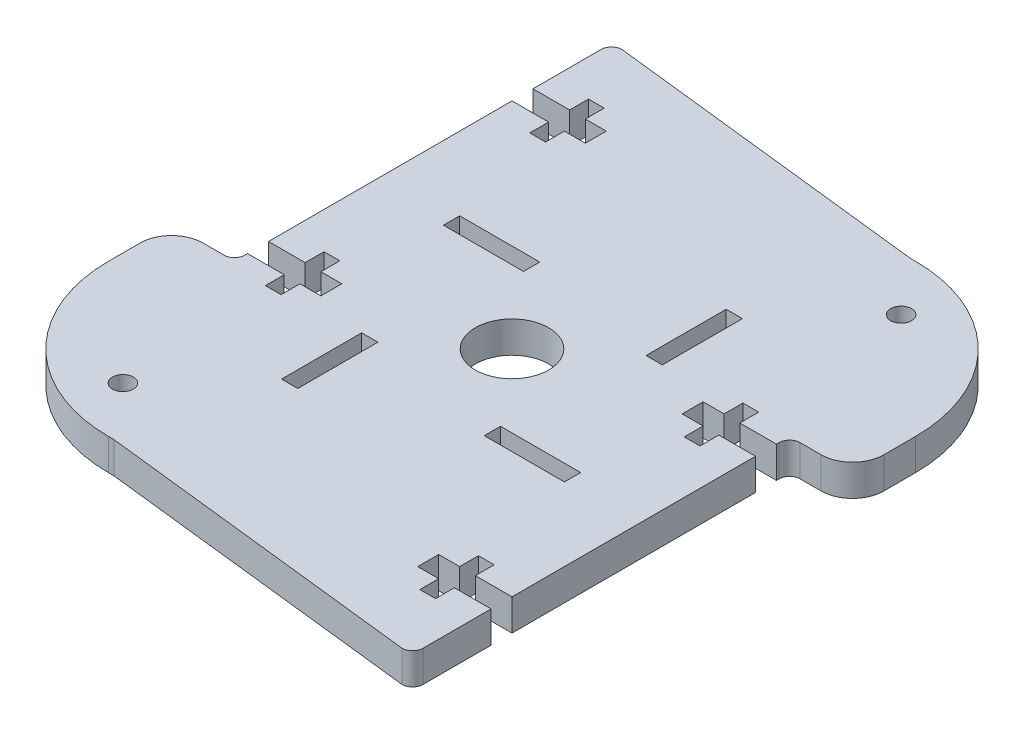
from build123d import *

# Parameters (mm, degrees)
ESBO_O1_W                = 53
ESBO_O1_H                = 60
RESSALTO_EXTRUS_O1_DEPTH = 3
ESBO_O4_W                = 1.55
ESBO_O4_H                = 7.65
ESBO_O4_W_2              = 7.65
ESBO_O4_H_2              = 1.55
CORTE_EXTRUS_O2_DEPTH    = 10
ESBO_O5_R                = 1
CORTE_EXTRUS_O3_DEPTH    = 41.140378673
ESBO_O7_R                = 3.5
CORTE_EXTRUS_O6_DEPTH    = 41.140378673
ESBO_O8_W                = 6
ESBO_O8_H                = 36
CORTE_EXTRUS_O7_DEPTH    = 41.140378673
FILETE2_R                = 3
FILETE3_R                = 1
CORTE_EXTRUS_O8_DEPTH    = 41.140378673
CORTE_EXTRUS_O9_DEPTH    = 41.140378673


with BuildPart() as part:
    # Esboço1 → Ressalto-extrusão1 (new body)
    with BuildSketch(Plane(origin=(0, 0, 0), x_dir=(1, 0, 0), z_dir=(0, 1, 0))):
        Rectangle(ESBO_O1_W, ESBO_O1_H)
    extrude(amount=RESSALTO_EXTRUS_O1_DEPTH)

    # Esboço4 → Corte-extrusão2 (cut)
    with BuildSketch(Plane(origin=(0, 3, 0), x_dir=(-1, 0, 0), z_dir=(0, 1, 0))):
        with Locations((-7.725, -9.675)):
            Rectangle(ESBO_O4_W, ESBO_O4_H)
        with Locations((-9.675, 7.725)):
            Rectangle(ESBO_O4_W_2, ESBO_O4_H_2)
        with Locations((7.725, 9.675)):
            Rectangle(ESBO_O4_W, ESBO_O4_H)
        with Locations((9.675, -7.725)):
            Rectangle(ESBO_O4_W_2, ESBO_O4_H_2)
    extrude(amount=-CORTE_EXTRUS_O2_DEPTH, mode=Mode.SUBTRACT)

    # Esboço5 → Corte-extrusão3 (cut, through all)
    with BuildSketch(Plane(origin=(0, 3, 0), x_dir=(1, 0, 0), z_dir=(0, 1, 0))):
        with Locations(Location((-15.742640687, -21.399494937, 0), (0, 0, 270))):
            Circle(ESBO_O5_R)
        with Locations(Location((15.742640687, 21.399494937, 0), (0, 0, 270))):
            Circle(ESBO_O5_R)
    extrude(amount=-CORTE_EXTRUS_O3_DEPTH, mode=Mode.SUBTRACT)

    # Esboço7 → Corte-extrusão6 (cut, through all)
    with BuildSketch(Plane(origin=(0, 3, 0), x_dir=(1, 0, 0), z_dir=(0, 1, 0))):
        with Locations(Location((0, 0, 0), (0, 0, 270))):
            Circle(ESBO_O7_R)
    extrude(amount=-CORTE_EXTRUS_O6_DEPTH, mode=Mode.SUBTRACT)

    # Esboço8 → Corte-extrusão7 (cut, through all)
    with BuildSketch(Plane(origin=(0, 3, 0), x_dir=(1, 0, 0), z_dir=(0, 1, 0))):
        with Locations((23.5, -12)):
            Rectangle(ESBO_O8_W, ESBO_O8_H)
        with Locations((-23.5, 12)):
            Rectangle(ESBO_O8_W, ESBO_O8_H)
    extrude(amount=-CORTE_EXTRUS_O7_DEPTH, mode=Mode.SUBTRACT)

    # Filete2
    filete2_edges = [part.edges().sort_by_distance(p)[0] for p in [
        (26.5, 1.5, -6),
        (-26.5, 1.5, 6),
    ]]
    fillet(filete2_edges, radius=FILETE2_R)

    # Filete3
    filete3_edges = [part.edges().sort_by_distance(p)[0] for p in [
        (20.5, 1.5, 30),
        (20.5, 1.5, -6),
        (-20.5, 1.5, -30),
        (-20.5, 1.5, 6),
    ]]
    fillet(filete3_edges, radius=FILETE3_R)

    # Esboço9 → Corte-extrusão8 (cut, through all)
    with BuildSketch(Plane(origin=(0, 3, 0), x_dir=(1, 0, 0), z_dir=(0, 1, 0))):
        Polygon((-13.5, 20.5), (-15.5, 20.5), (-15.5, 18.7), (-17, 18.7), (-17, 20.5), (-20.5, 20.5), (-20.5, 22.5), (-17, 22.5), (-17, 24.3), (-15.5, 24.3), (-15.5, 22.5), (-13.5, 22.5), align=None)
        Polygon((-13.5, -4.74347437), (-15.5, -4.74347437), (-15.5, -6.54347437), (-17, -6.54347437), (-17, -4.74347437), (-20.5, -4.74347437), (-20.5, -2.74347437), (-17, -2.74347437), (-17, -0.94347437), (-15.5, -0.94347437), (-15.5, -2.74347437), (-13.5, -2.74347437), align=None)
        Polygon((13.5, -20.5), (15.5, -20.5), (15.5, -18.7), (17, -18.7), (17, -20.5), (20.5, -20.5), (20.5, -22.5), (17, -22.5), (17, -24.3), (15.5, -24.3), (15.5, -22.5), (13.5, -22.5), align=None)
        Polygon((13.5, 4.74347437), (15.5, 4.74347437), (15.5, 6.54347437), (17, 6.54347437), (17, 4.74347437), (20.5, 4.74347437), (20.5, 2.74347437), (17, 2.74347437), (17, 0.94347437), (15.5, 0.94347437), (15.5, 2.74347437), (13.5, 2.74347437), align=None)
    extrude(amount=-CORTE_EXTRUS_O8_DEPTH, mode=Mode.SUBTRACT)

    # Esboço10 → Corte-extrusão9 (cut, through all)
    with BuildSketch(Plane(origin=(0, 3, 0), x_dir=(1, 0, 0), z_dir=(0, 1, 0))):
        with BuildLine():
            Line((26.5, 11.5), (26.5, 12))
            ThreePointArc((26.5, 12), (22.253048327, 22.253048327), (12, 26.5))
            Line((12, 26.5), (11.5, 26.5))
            Line((11.5, 26.5), (-19.5, 30))
            Line((-19.5, 30), (-19.5, 39.997592749))
            Line((-19.5, 39.997592749), (32.53430666, 39.997592749))
            Line((32.53430666, 39.997592749), (32.53430666, 11.5))
            Line((32.53430666, 11.5), (26.5, 11.5))
        make_face()
        with BuildLine():
            Line((-26.5, -11.5), (-26.5, -12))
            ThreePointArc((-26.5, -12), (-22.253048327, -22.253048327), (-12, -26.5))
            Line((-12, -26.5), (-11.5, -26.5))
            Line((-11.5, -26.5), (19.5, -30))
            Line((19.5, -30), (19.5, -39.997592749))
            Line((19.5, -39.997592749), (-32.53430666, -39.997592749))
            Line((-32.53430666, -39.997592749), (-32.53430666, -11.5))
            Line((-32.53430666, -11.5), (-26.5, -11.5))
        make_face()
    extrude(amount=-CORTE_EXTRUS_O9_DEPTH, mode=Mode.SUBTRACT)


solid = part.part
